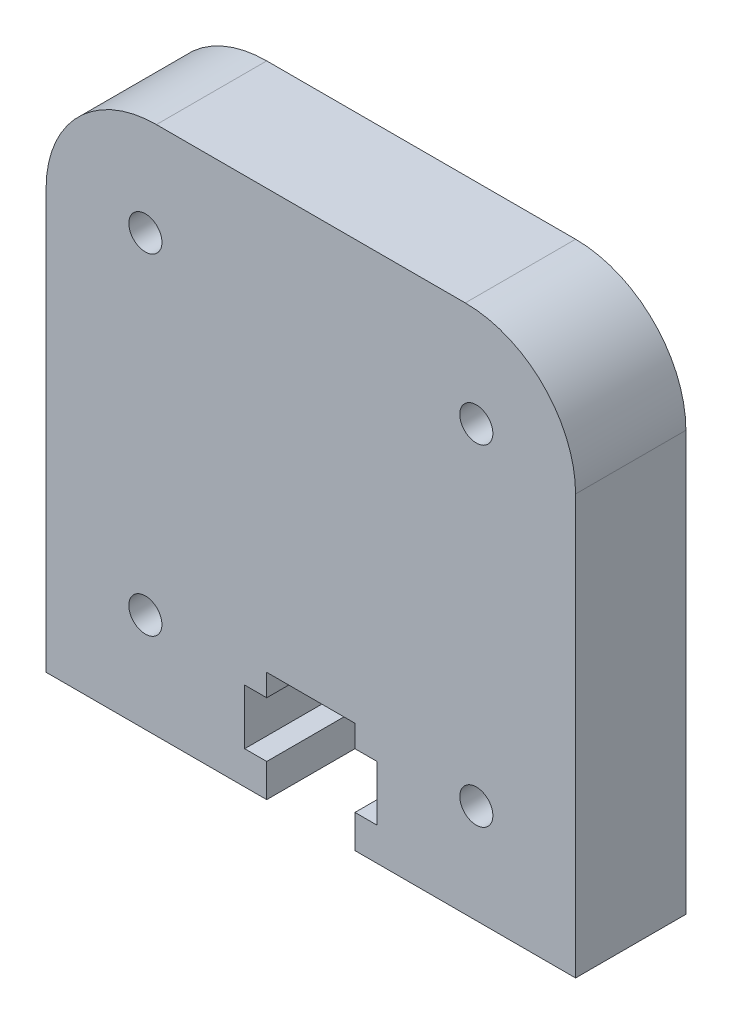
from build123d import *

# Parameters (mm, degrees)
SKETCH1_W           = 24
SKETCH1_H           = 24
SKETCH1_R           = 0.75
BOSS_EXTRUDE1_DEPTH = 5
FILLET1_R           = 5
CUT_EXTRUDE1_DEPTH  = 10


with BuildPart() as part:
    # Sketch1 → Boss-Extrude1 (new body)
    with BuildSketch(Plane.XY):
        Rectangle(SKETCH1_W, SKETCH1_H)
        with Locations((-7.5, 7.5)):
            Circle(SKETCH1_R, mode=Mode.SUBTRACT)
        with Locations((7.5, 7.5)):
            Circle(SKETCH1_R, mode=Mode.SUBTRACT)
        with Locations((7.5, -7.5)):
            Circle(SKETCH1_R, mode=Mode.SUBTRACT)
        with Locations((-7.5, -7.5)):
            Circle(SKETCH1_R, mode=Mode.SUBTRACT)
    extrude(amount=BOSS_EXTRUDE1_DEPTH)

    # Fillet1
    fillet1_edges = [part.edges().sort_by_distance(p)[0] for p in [
        (-12, 12, 2.5),
        (12, 12, 2.5),
    ]]
    fillet(fillet1_edges, radius=FILLET1_R)

    # Sketch2 → Cut-Extrude1 (cut)
    with BuildSketch(Plane.XY.offset(5)):
        Polygon((-2, -12), (-2, -10.5), (-3, -10.5), (-3, -8), (-2, -8), (-2, -7), (2, -7), (2, -8), (3, -8), (3, -10.5), (2, -10.5), (2, -12), align=None)
    extrude(amount=-CUT_EXTRUDE1_DEPTH, mode=Mode.SUBTRACT)


solid = part.part
